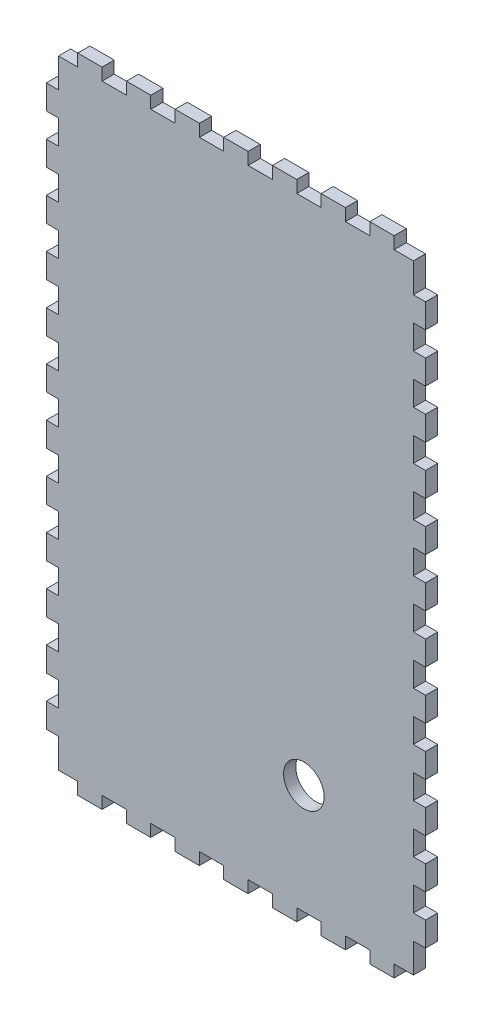
from build123d import *

# Parameters (mm, degrees)
SKETCH1_R           = 10
BOSS_EXTRUDE1_DEPTH = 6


with BuildPart() as part:
    # Sketch1 → Boss-Extrude1 (new body)
    with BuildSketch(Plane.XY):
        Polygon((78, 0), (78, -6), (66, -6), (66, 0), (54, 0), (54, -6), (42, -6), (42, 0), (30, 0), (30, -6), (18, -6), (18, 0), (6, 0), (6, -6), (-6, -6), (-6, 0), (-18, 0), (-18, -6), (-30, -6), (-30, 0), (-42, 0), (-42, -6), (-54, -6), (-54, 0), (-66, 0), (-66, -6), (-78, -6), (-78, 0), (-87.5, 0), (-87.5, 14.5), (-93.5, 14.5), (-93.5, 26.5), (-87.5, 26.5), (-87.5, 38.5), (-93.5, 38.5), (-93.5, 50.5), (-87.5, 50.5), (-87.5, 62.5), (-93.5, 62.5), (-93.5, 74.5), (-87.5, 74.5), (-87.5, 86.5), (-93.5, 86.5), (-93.5, 98.5), (-87.5, 98.5), (-87.5, 110.5), (-93.5, 110.5), (-93.5, 122.5), (-87.5, 122.5), (-87.5, 134.5), (-93.5, 134.5), (-93.5, 146.5), (-87.5, 146.5), (-87.5, 158.5), (-93.5, 158.5), (-93.5, 170.5), (-87.5, 170.5), (-87.5, 182.5), (-93.5, 182.5), (-93.5, 194.5), (-87.5, 194.5), (-87.5, 206.5), (-93.5, 206.5), (-93.5, 218.5), (-87.5, 218.5), (-87.5, 230.5), (-93.5, 230.5), (-93.5, 242.5), (-87.5, 242.5), (-87.5, 254.5), (-93.5, 254.5), (-93.5, 266.5), (-87.5, 266.5), (-87.5, 278.5), (-93.5, 278.5), (-93.5, 290.5), (-87.5, 290.5), (-87.5, 305), (-78, 305), (-78, 311), (-66, 311), (-66, 305), (-54, 305), (-54, 311), (-42, 311), (-42, 305), (-30, 305), (-30, 311), (-18, 311), (-18, 305), (-6, 305), (-6, 311), (6, 311), (6, 305), (18, 305), (18, 311), (30, 311), (30, 305), (42, 305), (42, 311), (54, 311), (54, 305), (66, 305), (66, 311), (78, 311), (78, 305), (87.5, 305), (87.5, 290.5), (93.5, 290.5), (93.5, 278.5), (87.5, 278.5), (87.5, 266.5), (93.5, 266.5), (93.5, 254.5), (87.5, 254.5), (87.5, 242.5), (93.5, 242.5), (93.5, 230.5), (87.5, 230.5), (87.5, 218.5), (93.5, 218.5), (93.5, 206.5), (87.5, 206.5), (87.5, 194.5), (93.5, 194.5), (93.5, 182.5), (87.5, 182.5), (87.5, 170.5), (93.5, 170.5), (93.5, 158.5), (87.5, 158.5), (87.5, 146.5), (93.5, 146.5), (93.5, 134.5), (87.5, 134.5), (87.5, 122.5), (93.5, 122.5), (93.5, 110.5), (87.5, 110.5), (87.5, 98.5), (93.5, 98.5), (93.5, 86.5), (87.5, 86.5), (87.5, 74.5), (93.5, 74.5), (93.5, 62.5), (87.5, 62.5), (87.5, 50.5), (93.5, 50.5), (93.5, 38.5), (87.5, 38.5), (87.5, 26.5), (93.5, 26.5), (93.5, 14.5), (87.5, 14.5), (87.5, 0), align=None)
        with Locations((33.5, 54)):
            Circle(SKETCH1_R, mode=Mode.SUBTRACT)
    extrude(amount=BOSS_EXTRUDE1_DEPTH)


solid = part.part
